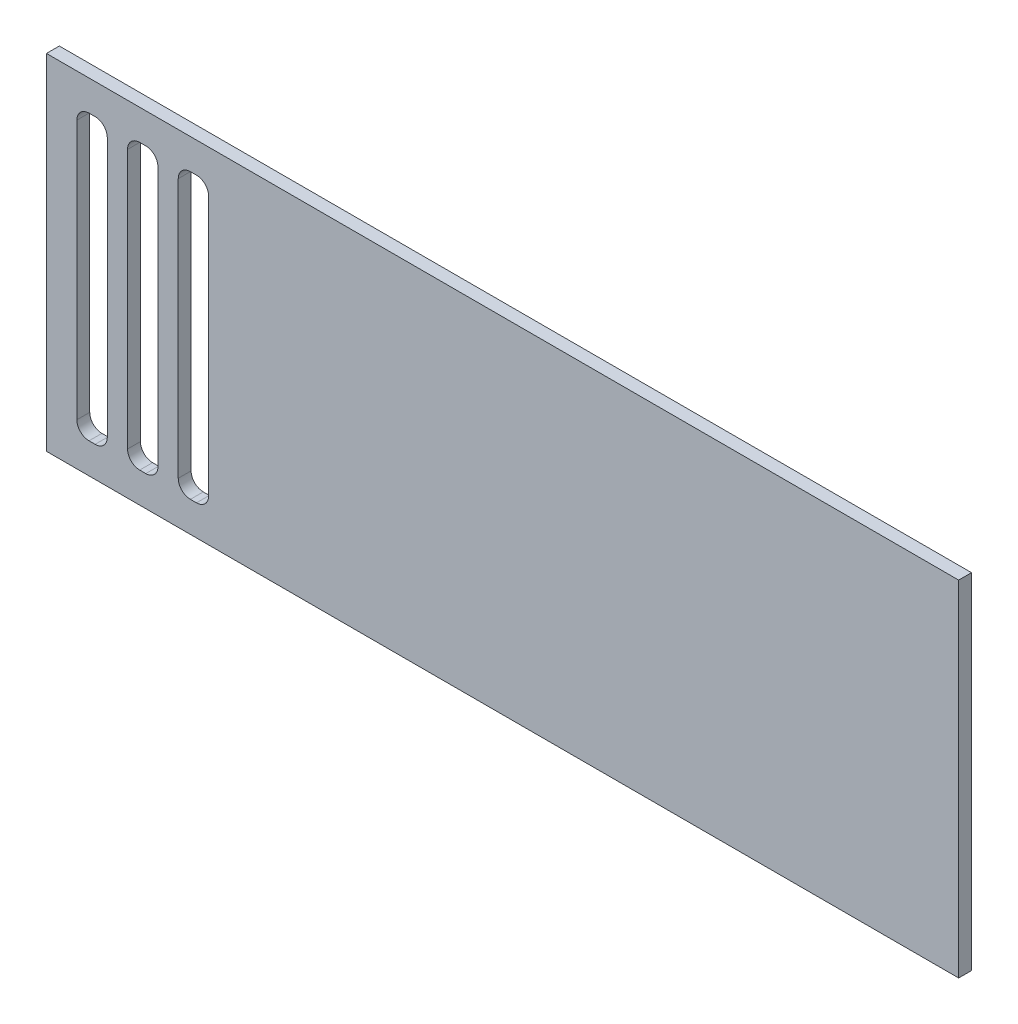
from build123d import *

# Parameters (mm, degrees)
SKETCH1_W               = 450
SKETCH1_H               = 170
BOSS_EXTRUDE1_DEPTH     = 6.35
SKETCH2_W               = 15
SKETCH2_H               = 140
CUT_EXTRUDE1_DEPTH      = 1
CUT_EXTRUDE1_DEPTH_BACK = 7.35
FILLET1_R               = 6
FILLET2_R               = 6


with BuildPart() as part:
    # Sketch1 → Boss-Extrude1 (new body)
    with BuildSketch(Plane.XY):
        with Locations((225, 85)):
            Rectangle(SKETCH1_W, SKETCH1_H)
    extrude(amount=BOSS_EXTRUDE1_DEPTH)

    # Sketch2 → Cut-Extrude1 (cut, two sides)
    with BuildSketch(Plane.XY.offset(6.35)) as cut_extrude1_sk:
        with Locations((22.5, 85)):
            Rectangle(SKETCH2_W, SKETCH2_H)
        with Locations((47.5, 85)):
            Rectangle(SKETCH2_W, SKETCH2_H)
        with Locations((72.5, 85)):
            Rectangle(SKETCH2_W, SKETCH2_H)
    extrude(amount=CUT_EXTRUDE1_DEPTH, mode=Mode.SUBTRACT)
    extrude(cut_extrude1_sk.sketch, amount=-CUT_EXTRUDE1_DEPTH_BACK, mode=Mode.SUBTRACT)

    # Fillet1
    fillet1_edges = [part.edges().sort_by_distance(p)[0] for p in [
        (15, 155, 3.175),
        (30, 155, 3.175),
        (40, 155, 3.175),
        (55, 155, 3.175),
        (80, 155, 3.175),
        (65, 155, 3.175),
    ]]
    fillet(fillet1_edges, radius=FILLET1_R)

    # Fillet2
    fillet2_edges = [part.edges().sort_by_distance(p)[0] for p in [
        (30, 15, 3.175),
        (15, 15, 3.175),
        (55, 15, 3.175),
        (40, 15, 3.175),
        (80, 15, 3.175),
        (65, 15, 3.175),
    ]]
    fillet(fillet2_edges, radius=FILLET2_R)


solid = part.part
